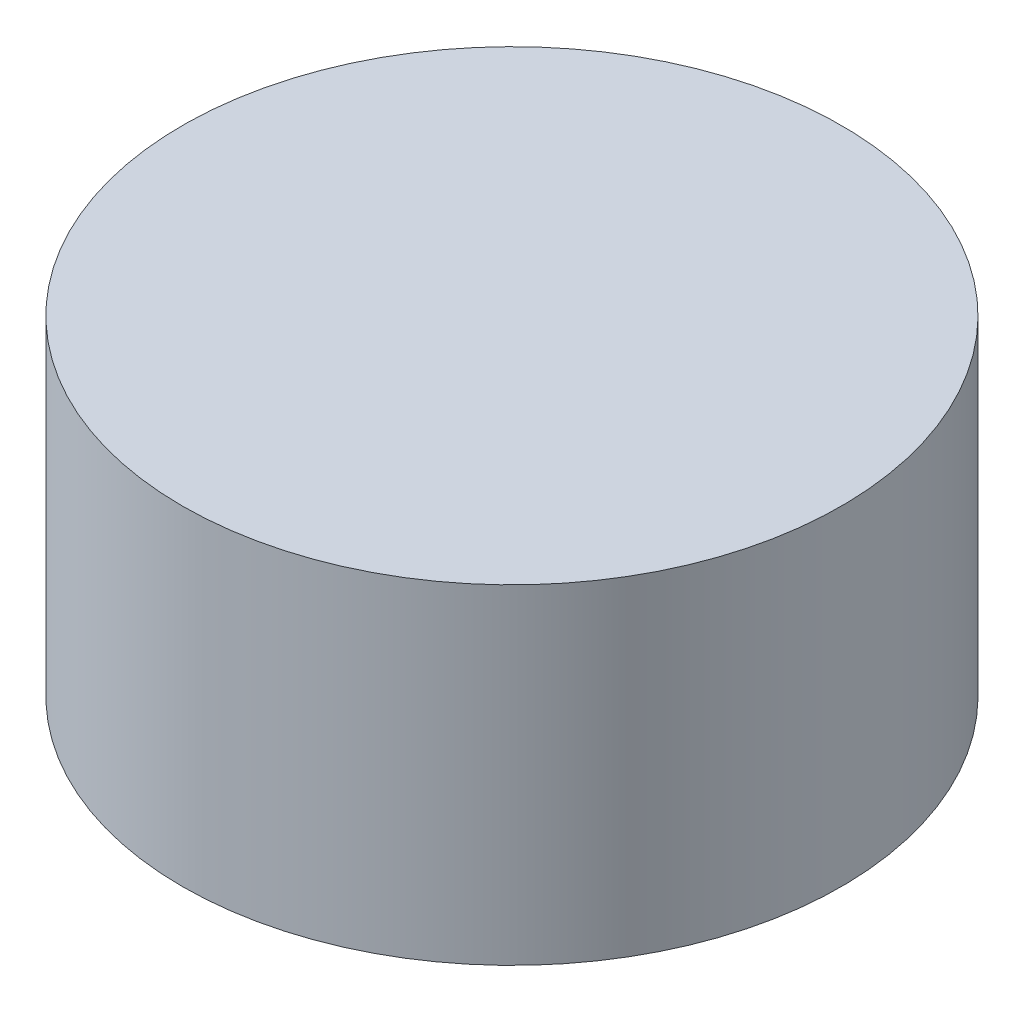
from build123d import *

# Parameters (mm, degrees)
SKETCH1_R           = 90
BOSS_EXTRUDE1_DEPTH = 90


with BuildPart() as part:
    # Sketch1 → Boss-Extrude1 (new body)
    with BuildSketch(Plane(origin=(0, 0, 0), x_dir=(1, 0, 0), z_dir=(0, 1, 0))):
        Circle(SKETCH1_R)
    extrude(amount=BOSS_EXTRUDE1_DEPTH)


solid = part.part
